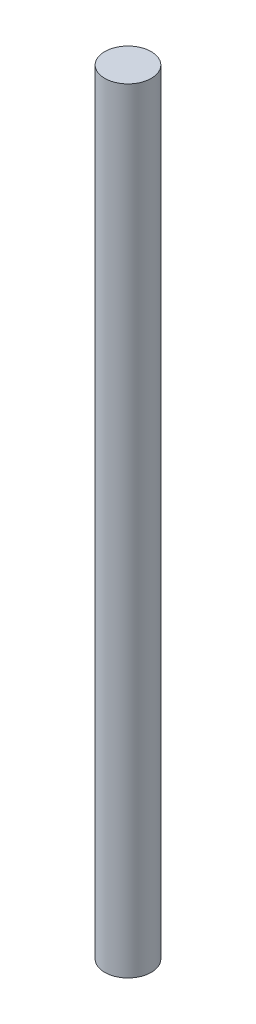
from build123d import *

# Parameters (mm, degrees)
SKETCH1_R           = 30
BOSS_EXTRUDE1_DEPTH = 1000


with BuildPart() as part:
    # Sketch1 → Boss-Extrude1 (new body)
    with BuildSketch(Plane(origin=(0, 0, 0), x_dir=(1, 0, 0), z_dir=(0, 1, 0))):
        Circle(SKETCH1_R)
    extrude(amount=BOSS_EXTRUDE1_DEPTH)


solid = part.part
